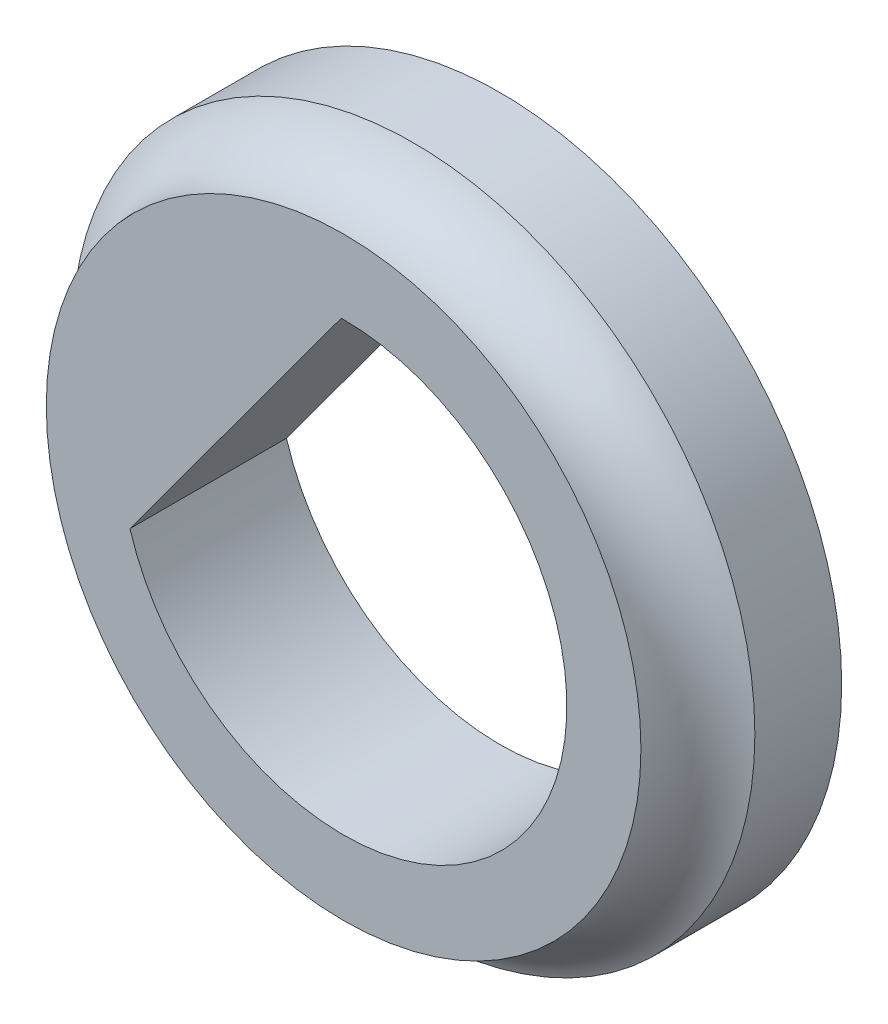
from build123d import *

# Parameters (mm, degrees)
SKETCH10_R              = 23.5
SKETCH10_R_2            = 18.200549451
CUT_EXTRUDE1_DEPTH      = 15
SKETCH11_W              = 34.097059432
SKETCH11_H              = 7.010776199
CUT_EXTRUDE2_DEPTH      = 16.299450549
CUT_EXTRUDE2_DEPTH_BACK = 16.299450549
BOSS_EXTRUDE1_DEPTH     = 7.010776


with BuildPart() as part:
    # Sketch1 → Revolve1 (revolve)
    with BuildSketch(Plane(origin=(0, 0, 0), x_dir=(0, 0, -1), z_dir=(1, 0, 0))):
        with BuildLine():
            Line((6.3, 23.5), (-6.3, 23.5))
            Line((-6.3, 23.5), (-7, 22.8))
            Line((-7, 22.8), (-7, 18.200549451))
            Line((-7, 18.200549451), (-3.111111111, 18.200549451))
            ThreePointArc((-3.111111111, 18.200549451), (0, 20.182652918), (3.111111111, 18.200549451))
            Line((3.111111111, 18.200549451), (7, 18.200549451))
            Line((7, 18.200549451), (7, 22.8))
            Line((7, 22.8), (6.3, 23.5))
        make_face()
    revolve(axis=Axis((0, 0, 7), (0, 0, -1)))

    # Sketch10 → Cut-Extrude1 (cut, through all)
    with BuildSketch(Plane(origin=(0, 0, -7), x_dir=(-1, 0, 0), z_dir=(0, 0, -1))):
        Circle(SKETCH10_R)
        Circle(SKETCH10_R_2, mode=Mode.SUBTRACT)
    extrude(amount=-CUT_EXTRUDE1_DEPTH, mode=Mode.SUBTRACT)


with BuildPart() as body_2:
    # Sketch3 → Revolve3 (revolve)
    with BuildSketch(Plane(origin=(0, 0, 0), x_dir=(0, 0, -1), z_dir=(1, 0, 0))):
        with BuildLine():
            Line((-7, 15.299450549), (-3.111111111, 15.299450549))
            ThreePointArc((-3.111111111, 15.299450549), (0, 13.317347082), (3.111111111, 15.299450549))
            Line((3.111111111, 15.299450549), (7, 15.299450549))
            Line((7, 15.299450549), (7, 10.7))
            Line((7, 10.7), (7, 10))
            Line((7, 10), (6.3, 10))
            Line((6.3, 10), (-6.3, 10))
            Line((-6.3, 10), (-7, 10))
            Line((-7, 10), (-7, 10.7))
            Line((-7, 10.7), (-7, 15.299450549))
        make_face()
    revolve(axis=Axis((0, 0, 7), (0, 0, -1)))

    # Sketch11 → Cut-Extrude2 (cut, two sides)
    with BuildSketch(Plane(origin=(0, 0, 0), x_dir=(1, 0, 0), z_dir=(0, 1, 0))) as cut_extrude2_sk:
        with Locations((-1.749079167, -3.516164298)):
            Rectangle(SKETCH11_W, SKETCH11_H)
    extrude(amount=CUT_EXTRUDE2_DEPTH, mode=Mode.SUBTRACT)
    extrude(cut_extrude2_sk.sketch, amount=-CUT_EXTRUDE2_DEPTH_BACK, mode=Mode.SUBTRACT)

    # Sketch12 → Boss-Extrude1 (add, through all)
    with BuildSketch(Plane.XY.offset(0.010776198)):
        with BuildLine():
            Line((-0.102639914, 9.999473239), (-9.570755133, -2.898386825))
            ThreePointArc((-9.570755133, -2.898386825), (-8.061162539, 5.917572012), (-0.102639914, 9.999473239))
        make_face()
    extrude(amount=-BOSS_EXTRUDE1_DEPTH)


solid = body_2.part
